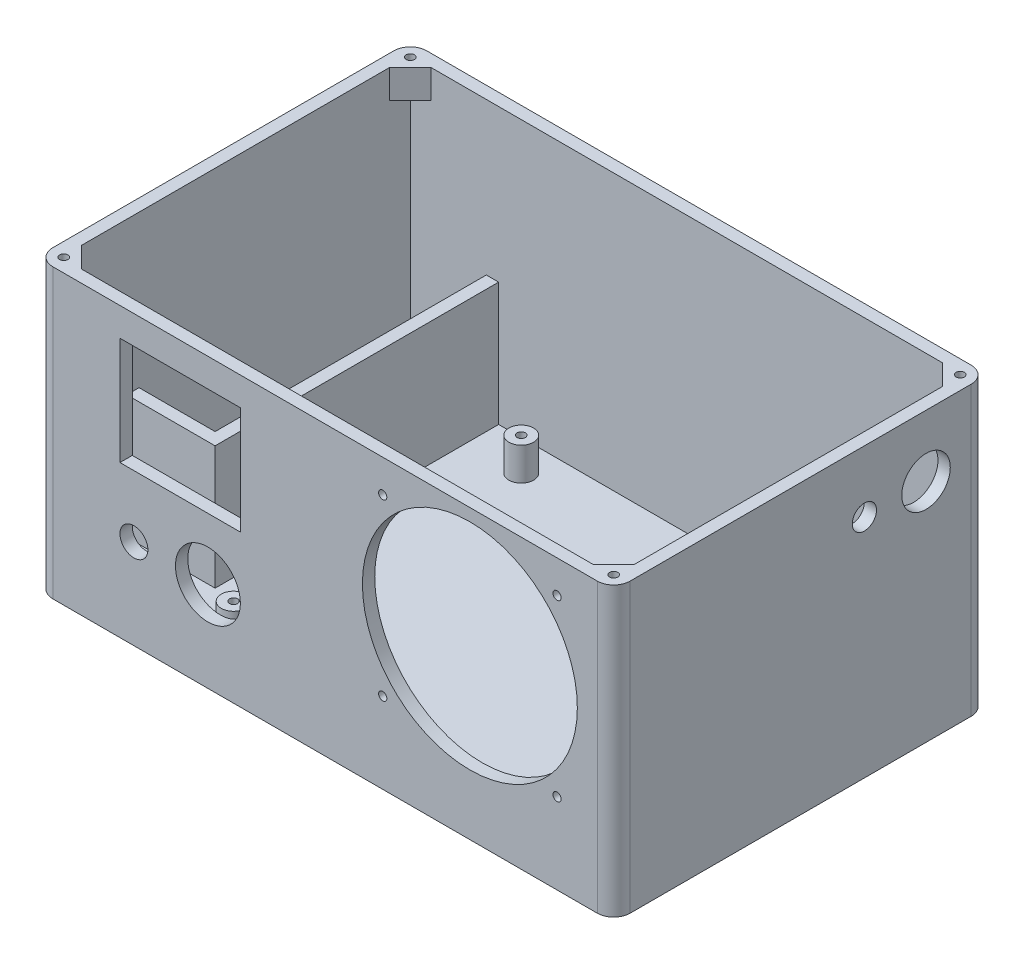
from build123d import *

# Parameters (mm, degrees)
SKETCH1_W                 = 134.5
SKETCH1_H                 = 85
BOSS_EXTRUDE1_DEPTH       = 3
SKETCH2_W                 = 140.5
SKETCH2_H                 = 91
SKETCH2_W_2               = 134.5
SKETCH2_H_2               = 85
BOSS_EXTRUDE2_DEPTH       = 70
BOSS_EXTRUDE3_START       = 5
SKETCH3_W                 = 100
SKETCH3_H                 = 80
BOSS_EXTRUDE3_DEPTH       = 5
SKETCH5_W                 = 3
SKETCH5_H                 = 66
BOSS_EXTRUDE5_DEPTH       = 30
SKETCH6_R                 = 3
SKETCH6_R_2               = 1
BOSS_EXTRUDE6_DEPTH       = 10
SKETCH7_W                 = 100
SKETCH7_H                 = 80
CUT_EXTRUDE2_DEPTH        = 10
SKETCH6_2_R               = 3
SKETCH6_2_R_2             = 1
BOSS_EXTRUDE7_DEPTH       = 8
MIRROR4_COPY_1_SKETCH_R   = 3
MIRROR4_COPY_1_SKETCH_R_2 = 1
MIRROR4_COPY_1_DEPTH      = 8
SKETCH9_R                 = 26.15
SKETCH9_W                 = 29.3
SKETCH9_H                 = 26.2
SKETCH9_R_2               = 1
SKETCH9_R_3               = 3.4
SKETCH9_R_4               = 7.9
CUT_EXTRUDE3_DEPTH        = 3
SKETCH10_R                = 2.95
SKETCH10_R_2              = 5.9
CUT_EXTRUDE4_DEPTH        = 3
BOSS_EXTRUDE8_DEPTH       = 7
FILLET1_R                 = 4
CUT_EXTRUDE6_DEPTH        = 5


with BuildPart() as part:
    # Sketch1 → Boss-Extrude1 (new body)
    with BuildSketch(Plane(origin=(0, 0, 0), x_dir=(1, 0, 0), z_dir=(0, 1, 0))):
        with Locations((-12.25, 0)):
            Rectangle(SKETCH1_W, SKETCH1_H)
    extrude(amount=BOSS_EXTRUDE1_DEPTH)

    # Sketch2 → Boss-Extrude2 (add)
    with BuildSketch(Plane(origin=(0, 0, 0), x_dir=(1, 0, 0), z_dir=(0, 1, 0))):
        with Locations((-12.25, 0)):
            Rectangle(SKETCH2_W, SKETCH2_H)
        with Locations((-12.25, 0)):
            Rectangle(SKETCH2_W_2, SKETCH2_H_2, mode=Mode.SUBTRACT)
    extrude(amount=BOSS_EXTRUDE2_DEPTH)

    # Sketch5 → Boss-Extrude5 (add)
    with BuildSketch(Plane(origin=(0, 3, 0), x_dir=(1, 0, 0), z_dir=(0, 1, 0))):
        Polygon((-58, -26.5), (-58, -23.5), (-61, -23.5), (-79.5, -23.5), (-79.5, -26.5), align=None)
        with Locations((-59.5, 9.5)):
            Rectangle(SKETCH5_W, SKETCH5_H)
    extrude(amount=BOSS_EXTRUDE5_DEPTH)



with BuildPart() as body_2:
    # Sketch3 → Boss-Extrude3 (new body)
    with BuildSketch(Plane(origin=(0, 3, 0), x_dir=(1, 0, 0), z_dir=(0, 1, 0)).offset(BOSS_EXTRUDE3_START)):
        Rectangle(SKETCH3_W, SKETCH3_H)
    extrude(amount=BOSS_EXTRUDE3_DEPTH)


with BuildPart() as part_1:
    add(part.part)

    add(body_2.part)  # Boss-Extrude6 merges body 2
    # Sketch6 → Boss-Extrude6 (add)
    with BuildSketch(Plane(origin=(0, 3, 0), x_dir=(1, 0, 0), z_dir=(0, 1, 0))):
        with Locations((-45, -35)):
            Circle(SKETCH6_R)
        with Locations((-45, -35)):
            Circle(SKETCH6_R_2, mode=Mode.SUBTRACT)
    extrude(amount=BOSS_EXTRUDE6_DEPTH)

    # Sketch7 → Cut-Extrude2 (cut)
    with BuildSketch(Plane(origin=(0, 13, 0), x_dir=(1, 0, 0), z_dir=(0, 1, 0))):
        Rectangle(SKETCH7_W, SKETCH7_H)
    extrude(amount=-CUT_EXTRUDE2_DEPTH, mode=Mode.SUBTRACT)

    # Sketch6_2 → Boss-Extrude7 (add)
    with BuildSketch(Plane(origin=(0, 3, 0), x_dir=(1, 0, 0), z_dir=(0, 1, 0))):
        with Locations((-45, -35)):
            Circle(SKETCH6_2_R)
        with Locations((-45, -35)):
            Circle(SKETCH6_2_R_2, mode=Mode.SUBTRACT)
    boss_extrude7 = extrude(amount=BOSS_EXTRUDE7_DEPTH)

    # Mirror3: Boss-Extrude7 across plane
    add(boss_extrude7.mirror(Plane.XY))

    # Mirror4: Boss-Extrude7 across plane
    add(boss_extrude7.mirror(Plane(origin=(0, 0, 0), x_dir=(0, 0, 1), z_dir=(1, 0, 0))))

    # Mirror4 copy 1 sketch → Mirror4 copy 1 (add)
    with BuildSketch(Plane(origin=(0, 3, 0), x_dir=(-1, 0, 0), z_dir=(0, 1, 0))):
        with Locations((-45, -35)):
            Circle(MIRROR4_COPY_1_SKETCH_R)
        with Locations((-45, -35)):
            Circle(MIRROR4_COPY_1_SKETCH_R_2, mode=Mode.SUBTRACT)
    extrude(amount=MIRROR4_COPY_1_DEPTH)

    # Sketch9 → Cut-Extrude3 (cut)
    with BuildSketch(Plane.XY.offset(45.5)):
        with Locations((23, 40.85)):
            Circle(SKETCH9_R)
        with Locations((-47.5, 50)):
            Rectangle(SKETCH9_W, SKETCH9_H)
        with Locations((1.786796564, 62.063203436)):
            Circle(SKETCH9_R_2)
        with Locations((44.213203436, 62.063203436)):
            Circle(SKETCH9_R_2)
        with Locations((44.213203436, 19.636796564)):
            Circle(SKETCH9_R_2)
        with Locations((1.786796564, 19.636796564)):
            Circle(SKETCH9_R_2)
        with Locations((-58.75, 21.9)):
            Circle(SKETCH9_R_3)
        with Locations((-40.75, 21.9)):
            Circle(SKETCH9_R_4)
    extrude(amount=-CUT_EXTRUDE3_DEPTH, mode=Mode.SUBTRACT)

    # Sketch10 → Cut-Extrude4 (cut)
    with BuildSketch(Plane(origin=(58, 0, 0), x_dir=(0, 0, -1), z_dir=(1, 0, 0))):
        with Locations((15.5, 55)):
            Circle(SKETCH10_R)
        with Locations((30.5, 55)):
            Circle(SKETCH10_R_2)
    extrude(amount=-CUT_EXTRUDE4_DEPTH, mode=Mode.SUBTRACT)

    # Sketch11 → Boss-Extrude8 (add)
    with BuildSketch(Plane(origin=(0, 70, 0), x_dir=(1, 0, 0), z_dir=(0, 1, 0))):
        Polygon((-74.5, 42.5), (-79.5, 42.5), (-79.5, 37.5), align=None)
        Polygon((55, 37.5), (55, 42.5), (50, 42.5), align=None)
        Polygon((50, -42.5), (55, -42.5), (55, -37.5), align=None)
        Polygon((-79.5, -37.5), (-79.5, -42.5), (-74.5, -42.5), align=None)
    extrude(amount=-BOSS_EXTRUDE8_DEPTH)

    # Fillet1
    fillet1_edges = [part_1.edges().sort_by_distance(p)[0] for p in [
        (58, 35, 45.5),
        (58, 35, -45.5),
        (-82.5, 35, -45.5),
        (-82.5, 35, 45.5),
    ]]
    fillet(fillet1_edges, radius=FILLET1_R)

    # Sketch13 → Cut-Extrude6 (cut)
    with BuildSketch(Plane(origin=(0, 70, 0), x_dir=(1, 0, 0), z_dir=(0, 1, 0))):
        with BuildLine():
            ThreePointArc((55.371320344, 42.871320344), (53.957106781, 42.871320344), (53.957106781, 41.457106781))
            Line((53.957106781, 41.457106781), (55.371320344, 42.871320344))
        make_face()
        with BuildLine():
            Line((55.371320344, 42.871320344), (53.957106781, 41.457106781))
            ThreePointArc((53.957106781, 41.457106781), (55.046896995, 41.24033403), (55.664213562, 42.164213562))
            ThreePointArc((55.664213562, 42.164213562), (55.588093095, 42.546896995), (55.371320344, 42.871320344))
        make_face()
        with BuildLine():
            ThreePointArc((53.957106781, -41.457106781), (53.957106781, -42.871320344), (55.371320344, -42.871320344))
            Line((55.371320344, -42.871320344), (53.957106781, -41.457106781))
        make_face()
        with BuildLine():
            Line((53.957106781, -41.457106781), (55.371320344, -42.871320344))
            ThreePointArc((55.371320344, -42.871320344), (55.588093095, -42.546896995), (55.664213562, -42.164213562))
            ThreePointArc((55.664213562, -42.164213562), (55.046896995, -41.24033403), (53.957106781, -41.457106781))
        make_face()
        with BuildLine():
            ThreePointArc((-78.164213562, -42.164213562), (-78.24033403, -41.78153013), (-78.457106781, -41.457106781))
            Line((-78.457106781, -41.457106781), (-79.871320344, -42.871320344))
            ThreePointArc((-79.871320344, -42.871320344), (-78.78153013, -43.088093095), (-78.164213562, -42.164213562))
        make_face()
        with BuildLine():
            Line((-79.871320344, -42.871320344), (-78.457106781, -41.457106781))
            ThreePointArc((-78.457106781, -41.457106781), (-79.871320344, -41.457106781), (-79.871320344, -42.871320344))
        make_face()
        with BuildLine():
            ThreePointArc((-78.164213562, 42.164213562), (-78.78153013, 43.088093095), (-79.871320344, 42.871320344))
            Line((-79.871320344, 42.871320344), (-78.457106781, 41.457106781))
            ThreePointArc((-78.457106781, 41.457106781), (-78.24033403, 41.78153013), (-78.164213562, 42.164213562))
        make_face()
        with BuildLine():
            Line((-78.457106781, 41.457106781), (-79.871320344, 42.871320344))
            ThreePointArc((-79.871320344, 42.871320344), (-79.871320344, 41.457106781), (-78.457106781, 41.457106781))
        make_face()
    extrude(amount=-CUT_EXTRUDE6_DEPTH, mode=Mode.SUBTRACT)


solid = part_1.part
